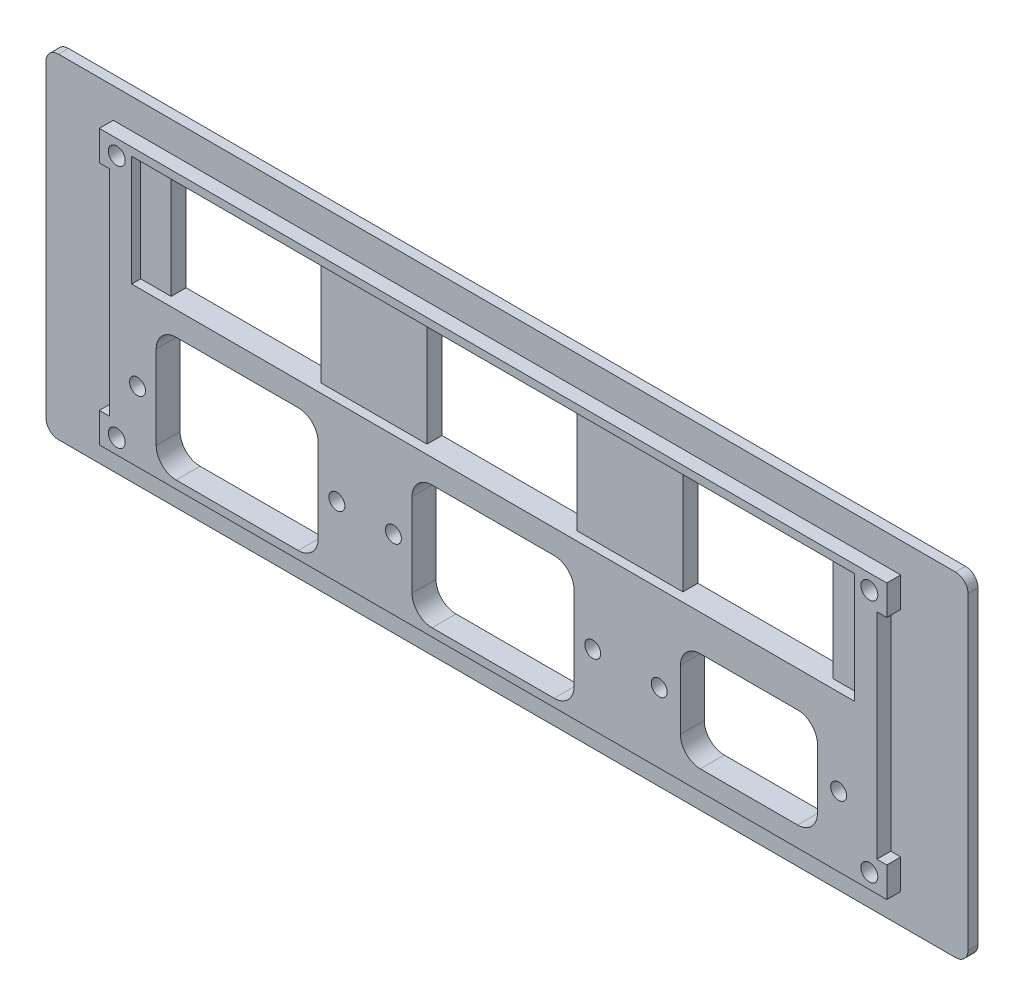
from build123d import *

# Parameters (mm, degrees)
P_IDAT_VYSUNUT_M1_DEPTH                           = 2
SKICA2_W                                          = 154
SKICA2_H                                          = 55
P_IDAT_VYSUNUT_M2_DEPTH                           = 2.8
SKICA3_R                                          = 1.6
SKICA3_W                                          = 30.1
SKICA3_H                                          = 22.2
ODEBRAT_VYSUNUT_M1_DEPTH                          = 5.8
SKICA4_W                                          = 145
SKICA4_H                                          = 22.2
ODEBRAT_VYSUNUT_M2_DEPTH                          = 1.8
SKICA5_W                                          = 2
SKICA5_H                                          = 6
P_IDAT_VYSUNUT_M3_DEPTH                           = 2.8
KU_ELOV_ZAHLOUBEN_PRO_M3_ROUBU_SE_Z_P_D           = 3.4
KU_ELOV_ZAHLOUBEN_PRO_M3_ROUBU_SE_Z_P_CSINK_D     = 6.3
KU_ELOV_ZAHLOUBEN_PRO_M3_ROUBU_SE_Z_P_CSINK_ANGLE = 90


with BuildPart() as part:
    # Skica1 → Přidat vysunutím1 (new body)
    with BuildSketch(Plane.XY):
        with BuildLine():
            Line((-90, 33.5), (90, 33.5))
            ThreePointArc((90, 33.5), (91.767766953, 32.767766953), (92.5, 31))
            Line((92.5, 31), (92.5, -31))
            ThreePointArc((92.5, -31), (91.767766953, -32.767766953), (90, -33.5))
            Line((90, -33.5), (-90, -33.5))
            ThreePointArc((-90, -33.5), (-91.767766953, -32.767766953), (-92.5, -31))
            Line((-92.5, -31), (-92.5, 31))
            ThreePointArc((-92.5, 31), (-91.767766953, 32.767766953), (-90, 33.5))
        make_face()
    extrude(amount=P_IDAT_VYSUNUT_M1_DEPTH)

    # Skica2 → Přidat vysunutím2 (add)
    with BuildSketch(Plane.XY.offset(2)):
        Rectangle(SKICA2_W, SKICA2_H)
    extrude(amount=P_IDAT_VYSUNUT_M2_DEPTH)

    # Skica3 → Odebrat vysunutím1 (cut, through all)
    with BuildSketch(Plane.XY.offset(4.8)):
        with Locations((-20, -13.5)):
            Circle(SKICA3_R)
        with Locations((20, -13.5)):
            Circle(SKICA3_R)
        with Locations((33.34, -13.5)):
            Circle(SKICA3_R)
        with Locations((69.34, -13.5)):
            Circle(SKICA3_R)
        with Locations((-31.34, -13.5)):
            Circle(SKICA3_R)
        with Locations((-71.34, -13.5)):
            Circle(SKICA3_R)
        with BuildLine():
            Line((-39.09, -1.1), (-63.59, -1.1))
            ThreePointArc((-63.59, -1.1), (-66.418427125, -2.271572875), (-67.59, -5.1))
            Line((-67.59, -5.1), (-67.59, -21.9))
            ThreePointArc((-67.59, -21.9), (-66.418427125, -24.728427125), (-63.59, -25.9))
            Line((-63.59, -25.9), (-39.09, -25.9))
            ThreePointArc((-39.09, -25.9), (-36.261572875, -24.728427125), (-35.09, -21.9))
            Line((-35.09, -21.9), (-35.09, -5.1))
            ThreePointArc((-35.09, -5.1), (-36.261572875, -2.271572875), (-39.09, -1.1))
        make_face()
        with BuildLine():
            Line((12.25, -1.1), (-12.25, -1.1))
            ThreePointArc((-12.25, -1.1), (-15.078427125, -2.271572875), (-16.25, -5.1))
            Line((-16.25, -5.1), (-16.25, -21.9))
            ThreePointArc((-16.25, -21.9), (-15.078427125, -24.728427125), (-12.25, -25.9))
            Line((-12.25, -25.9), (12.25, -25.9))
            ThreePointArc((12.25, -25.9), (15.078427125, -24.728427125), (16.25, -21.9))
            Line((16.25, -21.9), (16.25, -5.1))
            ThreePointArc((16.25, -5.1), (15.078427125, -2.271572875), (12.25, -1.1))
        make_face()
        with BuildLine():
            Line((61.09, -3.5), (41.59, -3.5))
            ThreePointArc((41.59, -3.5), (38.761572875, -4.671572875), (37.59, -7.5))
            Line((37.59, -7.5), (37.59, -19.5))
            ThreePointArc((37.59, -19.5), (38.761572875, -22.328427125), (41.59, -23.5))
            Line((41.59, -23.5), (61.09, -23.5))
            ThreePointArc((61.09, -23.5), (63.918427125, -22.328427125), (65.09, -19.5))
            Line((65.09, -19.5), (65.09, -7.5))
            ThreePointArc((65.09, -7.5), (63.918427125, -4.671572875), (61.09, -3.5))
        make_face()
        with Locations((-51.34, 14.8)):
            Rectangle(SKICA3_W, SKICA3_H)
        with Locations((0, 14.8)):
            Rectangle(SKICA3_W, SKICA3_H)
        with Locations((51.34, 14.8)):
            Rectangle(SKICA3_W, SKICA3_H)
    extrude(amount=-ODEBRAT_VYSUNUT_M1_DEPTH, mode=Mode.SUBTRACT)

    # Skica4 → Odebrat vysunutím2 (cut)
    with BuildSketch(Plane.XY.offset(4.8)):
        with Locations((0, 14.8)):
            Rectangle(SKICA4_W, SKICA4_H)
    extrude(amount=-ODEBRAT_VYSUNUT_M2_DEPTH, mode=Mode.SUBTRACT)

    # Skica5 → Přidat vysunutím3 (add)
    with BuildSketch(Plane.XY.offset(2)):
        with Locations((-78, 24.5)):
            Rectangle(SKICA5_W, SKICA5_H)
        with Locations((-78, -24.5)):
            Rectangle(SKICA5_W, SKICA5_H)
        with Locations((78, -24.5)):
            Rectangle(SKICA5_W, SKICA5_H)
        with Locations((78, 24.5)):
            Rectangle(SKICA5_W, SKICA5_H)
    extrude(amount=P_IDAT_VYSUNUT_M3_DEPTH)

    # Kuželové zahloubení pro M3 šroubu se zápustnou hlavou plochou1 (through all)
    with Locations(Plane(origin=(0, 0, 0), x_dir=(-1, 0, 0), z_dir=(0, 0, -1))):
        with Locations((-75.5, -24.5), (-75.5, 24.5), (75.5, 24.5), (75.5, -24.5)):
            CounterSinkHole(KU_ELOV_ZAHLOUBEN_PRO_M3_ROUBU_SE_Z_P_D / 2, KU_ELOV_ZAHLOUBEN_PRO_M3_ROUBU_SE_Z_P_CSINK_D / 2, counter_sink_angle=KU_ELOV_ZAHLOUBEN_PRO_M3_ROUBU_SE_Z_P_CSINK_ANGLE)


solid = part.part
